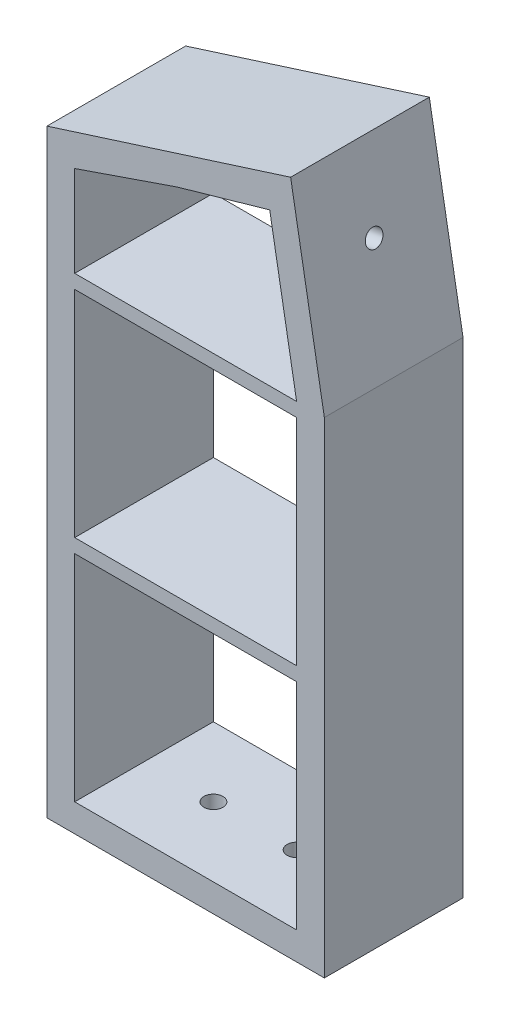
from build123d import *

# Parameters (mm, degrees)
BOSS_EXTRUDE1_DEPTH = 50
SKETCH4_R           = 3.15
CUT_EXTRUDE1_DEPTH  = 10
SKETCH10_R          = 3.425
CUT_EXTRUDE5_DEPTH  = 10
SKETCH12_W          = 80
SKETCH12_H          = 5
BOSS_EXTRUDE2_DEPTH = 50


with BuildPart() as part:
    # Sketch2 → Boss-Extrude1 (new body)
    with BuildSketch(Plane.XY):
        Polygon((-40.869025982, 215.979452737), (-40.869025982, 0), (59.130974018, 0), (59.130974018, 175), (46.975601581, 243.936542711), align=None)
        Polygon((0, 10), (49.130974018, 10), (49.130974018, 87.5), (49.130974018, 175), (39.440396213, 229.957997724), (6.085967265, 220.428944505), (-30.869025982, 207.731789579), (-30.869025982, 107.989726368), (-30.869025982, 10), align=None, mode=Mode.SUBTRACT)
    extrude(amount=BOSS_EXTRUDE1_DEPTH)

    # Sketch4 → Cut-Extrude1 (cut)
    with BuildSketch(Plane(origin=(87.274719522, 15.388887785, 0), x_dir=(0, 0, -1), z_dir=(0.984807753, 0.173648178, 0))):
        with Locations((-25, 202.690370895)):
            Circle(SKETCH4_R)
    extrude(amount=-CUT_EXTRUDE1_DEPTH, mode=Mode.SUBTRACT)

    # Sketch10 → Cut-Extrude5 (cut)
    with BuildSketch(Plane(origin=(0, 10, 0), x_dir=(1, 0, 0), z_dir=(0, 1, 0))):
        with Locations((-5.851287133, -25)):
            Circle(SKETCH10_R)
        with Locations((24.130974018, -25)):
            Circle(SKETCH10_R)
    extrude(amount=-CUT_EXTRUDE5_DEPTH, mode=Mode.SUBTRACT)

    # Sketch12 → Boss-Extrude2 (add)
    with BuildSketch(Plane.XY.offset(50)):
        with Locations((9.130974018, 172.5)):
            Rectangle(SKETCH12_W, SKETCH12_H)
        with Locations((9.130974018, 90)):
            Rectangle(SKETCH12_W, SKETCH12_H)
    extrude(amount=-BOSS_EXTRUDE2_DEPTH)


solid = part.part
